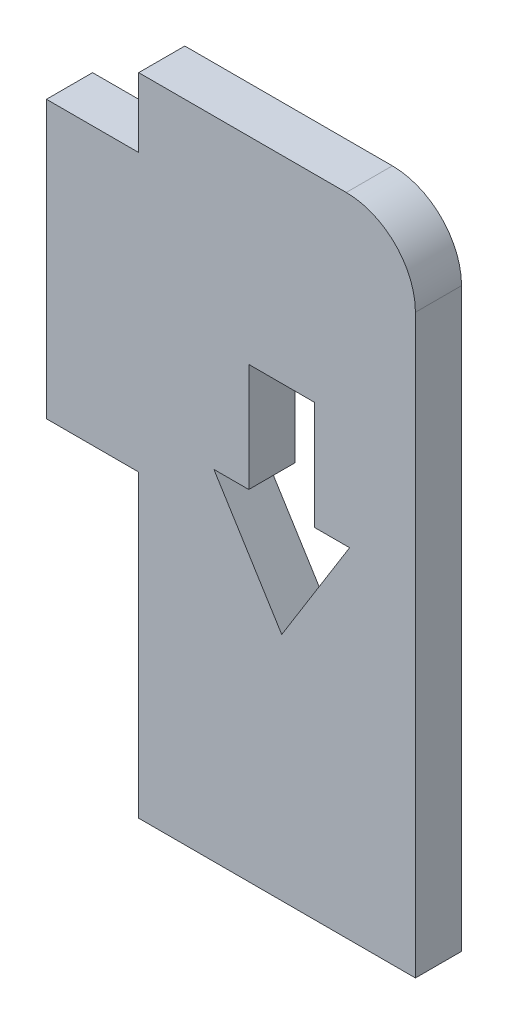
from build123d import *

# Parameters (mm, degrees)
EXTRUDE_1_DEPTH     = 2
CUT_EXTRUDE_1_DEPTH = 2
FILLET_1_R          = 3


with BuildPart() as part:
    # ｽｹｯﾁ1 → ﾎﾞｽ - 押し出し1 (new body)
    with BuildSketch(Plane.XY):
        Polygon((4, 0), (0, 0), (0, -12), (4, -12), (4, -25), (16, -25), (16, 3), (4, 3), align=None)
    extrude(amount=EXTRUDE_1_DEPTH)

    # ｽｹｯﾁ2 → ｶｯﾄ - 押し出し1 (cut)
    with BuildSketch(Plane.XY.offset(2)):
        Polygon((11.632823949, -5.570087609), (8.772941266, -5.570087609), (8.772941266, -10.268637818), (7.260776917, -10.268637818), (10.202882607, -14.99997105), (13.144988298, -10.268637818), (11.632823949, -10.268637818), align=None)
    extrude(amount=-CUT_EXTRUDE_1_DEPTH, mode=Mode.SUBTRACT)

    # ﾌｨﾚｯﾄ1
    fillet_1_edges = [part.edges().sort_by_distance(p)[0] for p in [
        (16, 3, 1),
    ]]
    fillet(fillet_1_edges, radius=FILLET_1_R)


solid = part.part
